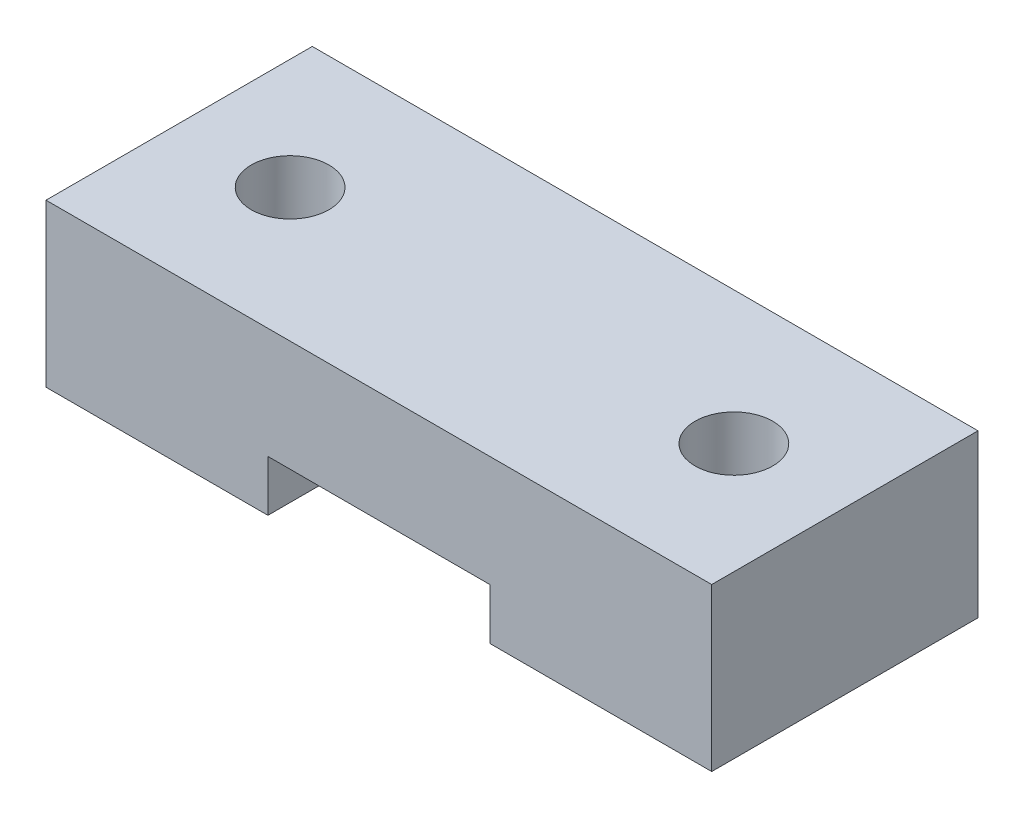
from build123d import *

# Parameters (mm, degrees)
SKETCH_1_W           = 30
SKETCH_1_H           = 61.5
EXTRUDE_1_DEPTH      = 5
SKETCH_2_R           = 1.75
SKETCH_2_W           = 21
SKETCH_2_H           = 41
CUT_EXTRUDE_1_DEPTH  = 6
SKETCH_3_W           = 30
SKETCH_3_H           = 40
EXTRUDE_2_DEPTH      = 5
SKETCH_4_R           = 1.75
CUT_EXTRUDE_2_DEPTH  = 62.5
SKETCH_5_W           = 10
SKETCH_5_H           = 12
EXTRUDE_3_DEPTH      = 2.3
SKETCH_6_W           = 30
SKETCH_6_H           = 12
EXTRUDE_4_DEPTH      = 4
EXTRUDE_5_DEPTH      = 4.5
FILLET_1_R           = 5
SKETCH_8_W           = 21
SKETCH_8_H           = 6
CUT_EXTRUDE_3_DEPTH  = 10
SKETCH_9_OUTSIDE_W   = 63.988
SKETCH_9_OUTSIDE_H   = 84.488
SKETCH_9_OUTSIDE_W_2 = 12
SKETCH_9_OUTSIDE_H_2 = 7.3
CUT_EXTRUDE_4_DEPTH  = 31


with BuildPart() as part:
    # ｽｹｯﾁ1 → ﾎﾞｽ - 押し出し1 (new body)
    with BuildSketch(Plane.XY):
        with Locations((15, 30.75)):
            Rectangle(SKETCH_1_W, SKETCH_1_H)
    extrude(amount=EXTRUDE_1_DEPTH)

    # ｽｹｯﾁ2 → ｶｯﾄ - 押し出し1 (cut, through all)
    with BuildSketch(Plane.XY.offset(5)):
        with Locations((10, 3.5)):
            Circle(SKETCH_2_R)
        with Locations((20, 3.5)):
            Circle(SKETCH_2_R)
        with Locations((10, 53)):
            Circle(SKETCH_2_R)
        with Locations((20, 53)):
            Circle(SKETCH_2_R)
        with Locations((15, 28.2)):
            Rectangle(SKETCH_2_W, SKETCH_2_H)
    extrude(amount=-CUT_EXTRUDE_1_DEPTH, mode=Mode.SUBTRACT)

    # ｽｹｯﾁ3 → ﾎﾞｽ - 押し出し2 (add)
    with BuildSketch(Plane(origin=(0, 61.5, 0), x_dir=(1, 0, 0), z_dir=(0, 1, 0))):
        with Locations((15, 20)):
            Rectangle(SKETCH_3_W, SKETCH_3_H)
    extrude(amount=-EXTRUDE_2_DEPTH)

    # ｽｹｯﾁ4 → ｶｯﾄ - 押し出し2 (cut, through all)
    with BuildSketch(Plane(origin=(0, 61.5, 0), x_dir=(1, 0, 0), z_dir=(0, 1, 0))):
        with Locations((5, 25)):
            Circle(SKETCH_4_R)
        with Locations((25, 25)):
            Circle(SKETCH_4_R)
    extrude(amount=-CUT_EXTRUDE_2_DEPTH, mode=Mode.SUBTRACT)

    # ｽｹｯﾁ5 → ﾎﾞｽ - 押し出し3 (add)
    with BuildSketch(Plane.XZ.offset(-56.5)):
        with Locations((5, -25)):
            Rectangle(SKETCH_5_W, SKETCH_5_H)
        Polygon((5, -28.6), (8.117691454, -26.8), (8.117691454, -23.2), (5, -21.4), (1.882308546, -23.2), (1.882308546, -26.8), align=None, mode=Mode.SUBTRACT)
        with Locations((25, -25)):
            Rectangle(SKETCH_5_W, SKETCH_5_H)
        Polygon((28.117691454, -26.8), (25, -28.6), (21.882308546, -26.8), (21.882308546, -23.2), (25, -21.4), (28.117691454, -23.2), align=None, mode=Mode.SUBTRACT)
    extrude(amount=EXTRUDE_3_DEPTH)

    # ｽｹｯﾁ6 → ﾎﾞｽ - 押し出し4 (add)
    with BuildSketch(Plane(origin=(0, 61.5, 0), x_dir=(1, 0, 0), z_dir=(0, 1, 0))):
        with Locations((15, 1)):
            Rectangle(SKETCH_6_W, SKETCH_6_H)
    extrude(amount=EXTRUDE_4_DEPTH)

    # ｽｹｯﾁ7 → ﾎﾞｽ - 押し出し5 (add)
    with BuildSketch(Plane(origin=(30, 0, 0), x_dir=(0, 0, -1), z_dir=(1, 0, 0))):
        Polygon((40, 56.5), (40, 39.5), (0, 9.822580645), (0, 21.5), (31, 44.5), (31, 56.5), align=None)
    extrude_5 = extrude(amount=-EXTRUDE_5_DEPTH)

    # ﾐﾗｰ1: ﾎﾞｽ - 押し出し5 across plane
    add(extrude_5.mirror(Plane.ZY.offset(-15)))

    # ﾌｨﾚｯﾄ1
    fillet_1_edges = [part.edges().sort_by_distance(p)[0] for p in [
        (30, 0, 2.5),
        (0, 0, 2.5),
    ]]
    fillet(fillet_1_edges, radius=FILLET_1_R)

    # ｽｹｯﾁ8 → ｶｯﾄ - 押し出し3 (cut, through all)
    with BuildSketch(Plane.XZ.offset(-56.5)):
        with Locations((15, -37)):
            Rectangle(SKETCH_8_W, SKETCH_8_H)
    extrude(amount=-CUT_EXTRUDE_3_DEPTH, mode=Mode.SUBTRACT)

    # ｽｹｯﾁ9 outside → ｶｯﾄ - 押し出し4 (cut, through all)
    with BuildSketch(Plane.ZY):
        with Locations((-17.5, 32.75)):
            Rectangle(SKETCH_9_OUTSIDE_W, SKETCH_9_OUTSIDE_H)
        with Locations((-25, 57.85)):
            Rectangle(SKETCH_9_OUTSIDE_W_2, SKETCH_9_OUTSIDE_H_2, mode=Mode.SUBTRACT)
    extrude(amount=-CUT_EXTRUDE_4_DEPTH, mode=Mode.SUBTRACT)


solid = part.part
